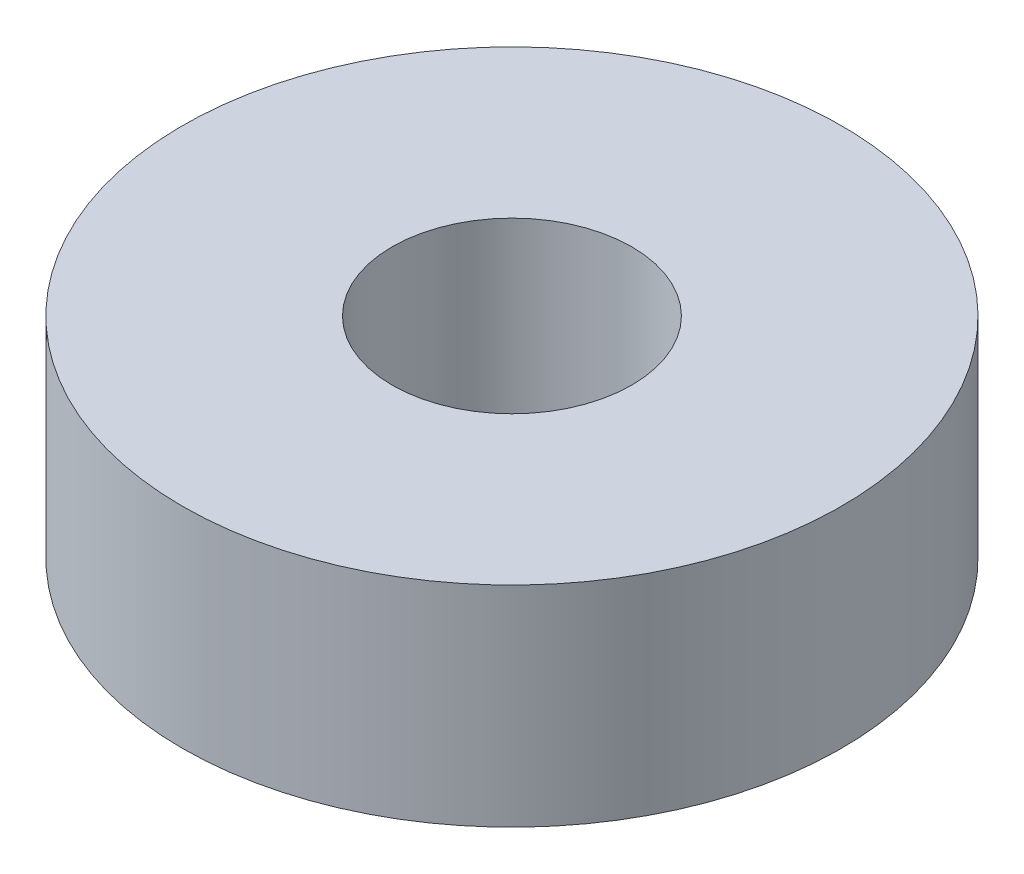
from build123d import *

# Parameters (mm, degrees)
ESBO_O1_R                = 11
ESBO_O1_R_2              = 4
RESSALTO_EXTRUS_O1_DEPTH = 7


with BuildPart() as part:
    # Esboço1 → Ressalto-extrusão1 (new body)
    with BuildSketch(Plane(origin=(0, 0, 0), x_dir=(1, 0, 0), z_dir=(0, 1, 0))):
        Circle(ESBO_O1_R)
        Circle(ESBO_O1_R_2, mode=Mode.SUBTRACT)
    extrude(amount=RESSALTO_EXTRUS_O1_DEPTH)


solid = part.part
